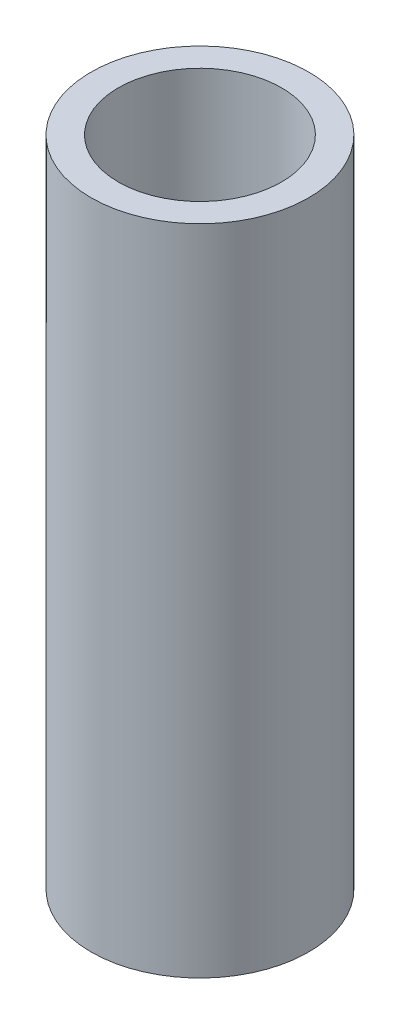
from build123d import *

# Parameters (mm, degrees)
SKETCH1_R           = 12.7
SKETCH1_R_2         = 9.525
BOSS_EXTRUDE2_DEPTH = 76.2


with BuildPart() as part:
    # Sketch1 → Boss-Extrude2 (new body)
    with BuildSketch(Plane(origin=(0, 0, 0), x_dir=(1, 0, 0), z_dir=(0, 1, 0))):
        with Locations((-391.181668083, 212.743279788)):
            Circle(SKETCH1_R)
        with Locations((-391.181668083, 212.743279788)):
            Circle(SKETCH1_R_2, mode=Mode.SUBTRACT)
    extrude(amount=BOSS_EXTRUDE2_DEPTH)


solid = part.part
